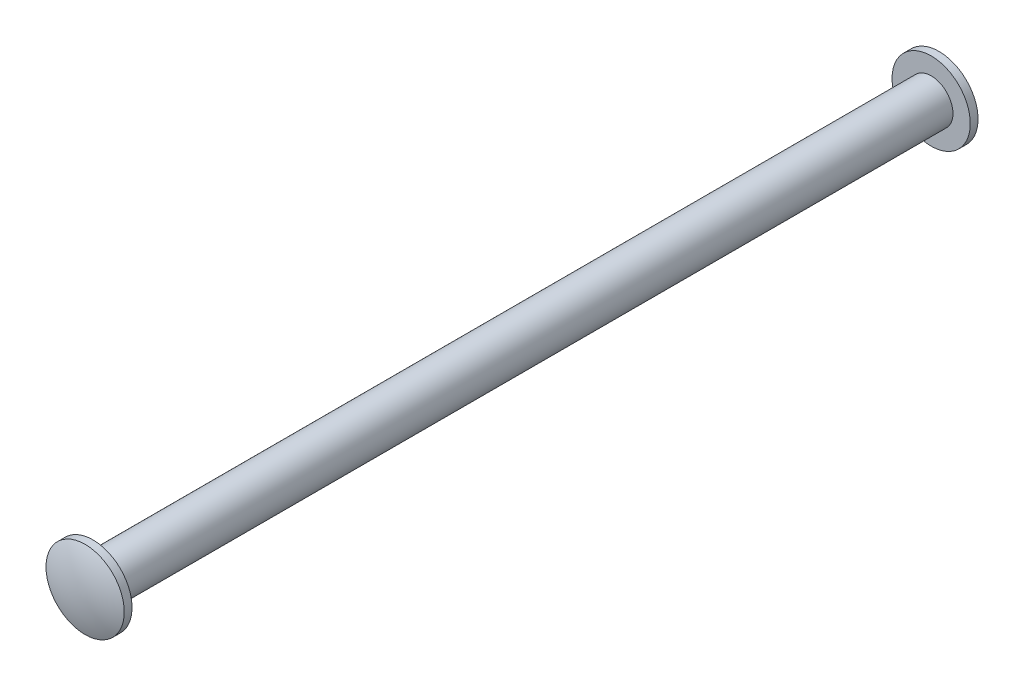
from build123d import *


with BuildPart() as part:
    # Sketch1 → Revolve1 (revolve)
    with BuildSketch(Plane.XZ):
        with BuildLine():
            Line((0, 39.51732), (0, -39.51732))
            ThreePointArc((0, -39.51732), (1.812962699, -39.338430068), (3.556, -38.80866))
            Line((3.556, -38.80866), (3.556, -38.1))
            Line((3.556, -38.1), (1.984375, -38.1))
            Line((1.984375, -38.1), (1.984375, 38.1))
            Line((1.984375, 38.1), (3.556, 38.1))
            Line((3.556, 38.1), (3.556, 38.80866))
            ThreePointArc((3.556, 38.80866), (1.812962699, 39.338430068), (0, 39.51732))
        make_face()
    revolve(axis=Axis((0, 0, 39.51732), (0, 0, -1)))


solid = part.part
